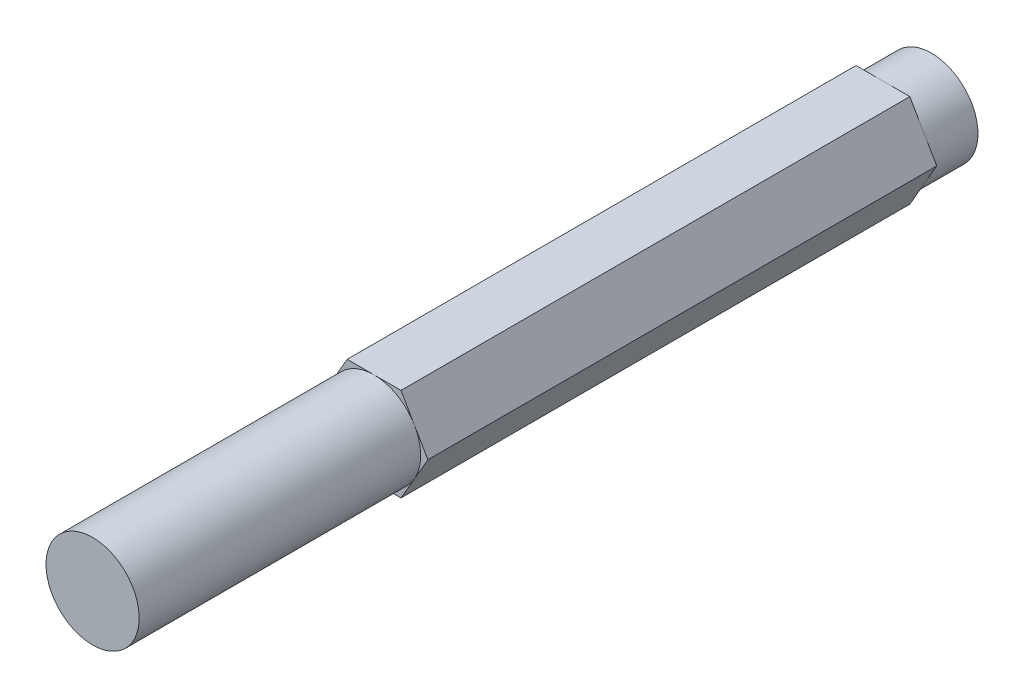
from build123d import *

# Parameters (mm, degrees)
BOSS_EXTRUDE1_DEPTH = 114.3
CUT_EXTRUDE1_DEPTH  = 6.604
CUT_EXTRUDE3_DEPTH  = 77.562920199


with BuildPart() as part:
    # Sketch1 → Boss-Extrude1 (new body)
    with BuildSketch(Plane.XY):
        Polygon((7.332348419, 0), (3.666174209, 6.35), (-3.666174209, 6.35), (-7.332348419, 0), (-3.666174209, -6.35), (3.666174209, -6.35), align=None)
    extrude(amount=BOSS_EXTRUDE1_DEPTH)

    # Sketch1_3 → Cut-Extrude1 (cut)
    with BuildSketch(Plane.XY):
        with BuildLine():
            Line((5.499261261, -3.175000092), (7.332348419, 0))
            Line((7.332348419, 0), (5.499261261, 3.175000092))
            ThreePointArc((5.499261261, 3.175000092), (6.35, 0), (5.499261261, -3.175000092))
        make_face()
        with BuildLine():
            ThreePointArc((0, 6.35), (3.174999954, 5.499261341), (5.499261261, 3.175000092))
            Line((5.499261261, 3.175000092), (3.666174209, 6.35))
            Line((3.666174209, 6.35), (0, 6.35))
        make_face()
        with BuildLine():
            Line((3.666174209, -6.35), (5.499261261, -3.175000092))
            ThreePointArc((5.499261261, -3.175000092), (3.174999954, -5.499261341), (0, -6.35))
            Line((0, -6.35), (3.666174209, -6.35))
        make_face()
        with BuildLine():
            ThreePointArc((-5.499261261, 3.175000092), (-3.174999954, 5.499261341), (0, 6.35))
            Line((0, 6.35), (-3.666174209, 6.35))
            Line((-3.666174209, 6.35), (-5.499261261, 3.175000092))
        make_face()
        with BuildLine():
            Line((-3.666174209, -6.35), (0, -6.35))
            ThreePointArc((0, -6.35), (-3.175000002, -5.499261313), (-5.499261317, -3.174999996))
            Line((-5.499261317, -3.174999996), (-3.666174209, -6.35))
        make_face()
        with BuildLine():
            ThreePointArc((-5.499261317, -3.174999996), (-6.35, 5.6e-08), (-5.499261261, 3.175000092))
            Line((-5.499261261, 3.175000092), (-7.332348419, 0))
            Line((-7.332348419, 0), (-5.499261317, -3.174999996))
        make_face()
    extrude(amount=CUT_EXTRUDE1_DEPTH, mode=Mode.SUBTRACT)

    # Sketch3 → Cut-Extrude3 (cut, through all)
    with BuildSketch(Plane(origin=(0, 0, 75.946), x_dir=(-1, 0, 0), z_dir=(0, 0, -1))):
        with BuildLine():
            Line((0, 6.35), (-3.666174209, 6.35))
            Line((-3.666174209, 6.35), (-5.499261441, 3.17499978))
            ThreePointArc((-5.499261441, 3.17499978), (-3.17500011, 5.499261251), (0, 6.35))
        make_face()
        with BuildLine():
            ThreePointArc((-5.499261441, -3.17499978), (-6.35, 0), (-5.499261441, 3.17499978))
            Line((-5.499261441, 3.17499978), (-7.332348419, 0))
            Line((-7.332348419, 0), (-5.499261441, -3.17499978))
        make_face()
        with BuildLine():
            Line((3.666174209, 6.35), (0, 6.35))
            ThreePointArc((0, 6.35), (3.175000128, 5.49926124), (5.499261462, 3.174999743))
            Line((5.499261462, 3.174999743), (3.666174209, 6.35))
        make_face()
        with BuildLine():
            ThreePointArc((0, -6.35), (-3.17500011, -5.499261251), (-5.499261441, -3.17499978))
            Line((-5.499261441, -3.17499978), (-3.666174209, -6.35))
            Line((-3.666174209, -6.35), (0, -6.35))
        make_face()
        with BuildLine():
            Line((7.332348419, 0), (5.499261462, 3.174999743))
            ThreePointArc((5.499261462, 3.174999743), (6.35, -2.95e-07), (5.499261168, -3.175000253))
            Line((5.499261168, -3.175000253), (7.332348419, 0))
        make_face()
        with BuildLine():
            ThreePointArc((5.499261168, -3.175000253), (3.174999873, -5.499261387), (0, -6.35))
            Line((0, -6.35), (3.666174209, -6.35))
            Line((3.666174209, -6.35), (5.499261168, -3.175000253))
        make_face()
    extrude(amount=-CUT_EXTRUDE3_DEPTH, mode=Mode.SUBTRACT)


solid = part.part
